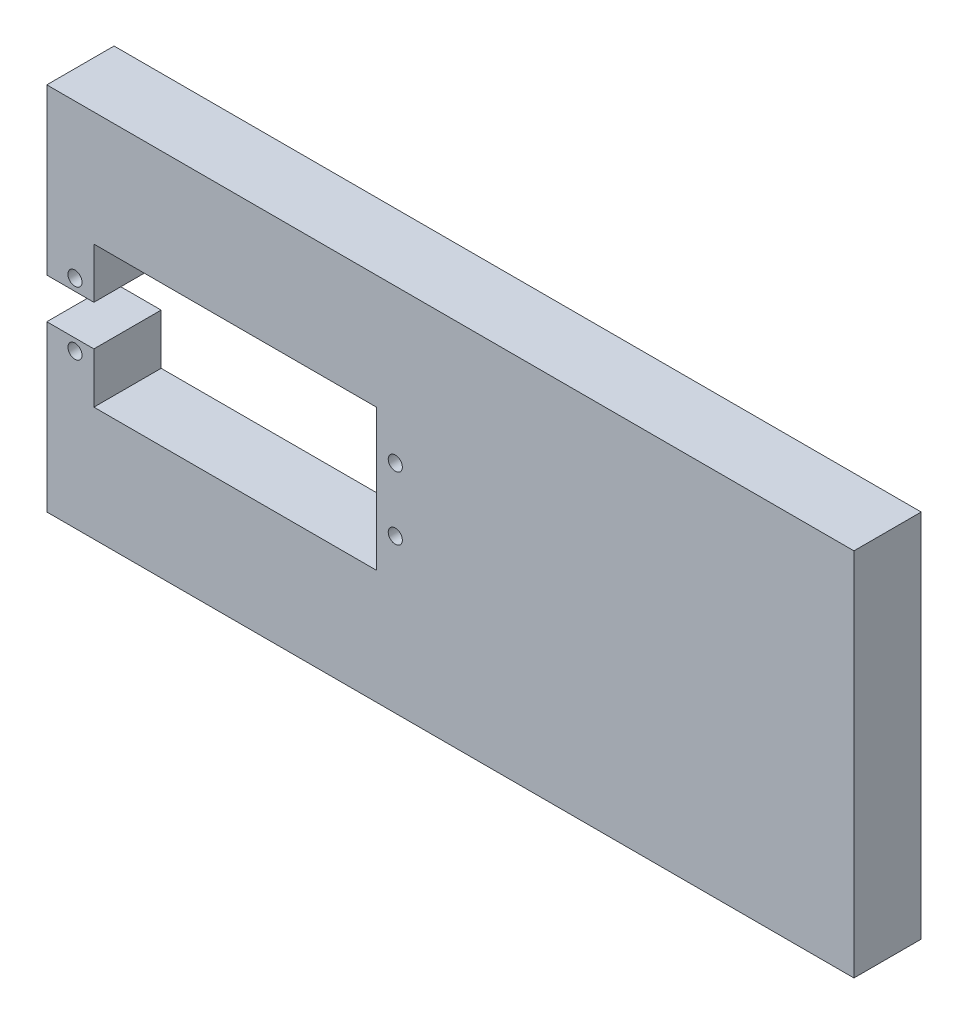
from build123d import *

# Parameters (mm, degrees)
SKETCH_1_R      = 1.05
EXTRUDE_1_DEPTH = 10


with BuildPart() as part:
    # 草圖1 → 填料-伸長1 (new body)
    with BuildSketch(Plane.XY):
        Polygon((-60, 27.5), (60, 27.5), (60, -27.5), (-60, -27.5), (-60, -3), (-53, -3), (-53, -10.5), (-11, -10.5), (-11, 10.5), (-53, 10.5), (-53, 3), (-60, 3), align=None)
        with Locations((-55.81, 4.7)):
            Circle(SKETCH_1_R, mode=Mode.SUBTRACT)
        with Locations((-8.19, 4.7)):
            Circle(SKETCH_1_R, mode=Mode.SUBTRACT)
        with Locations((-55.81, -4.7)):
            Circle(SKETCH_1_R, mode=Mode.SUBTRACT)
        with Locations((-8.19, -4.7)):
            Circle(SKETCH_1_R, mode=Mode.SUBTRACT)
    extrude(amount=EXTRUDE_1_DEPTH)


solid = part.part
